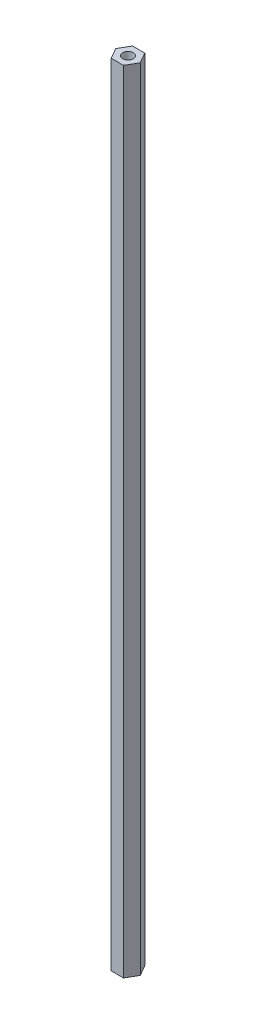
from build123d import *

# Parameters (mm, degrees)
SKETCH1_R           = 3.175
BOSS_EXTRUDE1_DEPTH = 472.44


with BuildPart() as part:
    # Sketch1 → Boss-Extrude1 (new body)
    with BuildSketch(Plane(origin=(0, 0, 0), x_dir=(1, 0, 0), z_dir=(0, 1, 0))):
        Polygon((3.666174209, -6.35), (7.332348419, 0), (3.666174209, 6.35), (-3.666174209, 6.35), (-7.332348419, 0), (-3.666174209, -6.35), align=None)
        Circle(SKETCH1_R, mode=Mode.SUBTRACT)
    extrude(amount=BOSS_EXTRUDE1_DEPTH)


solid = part.part
